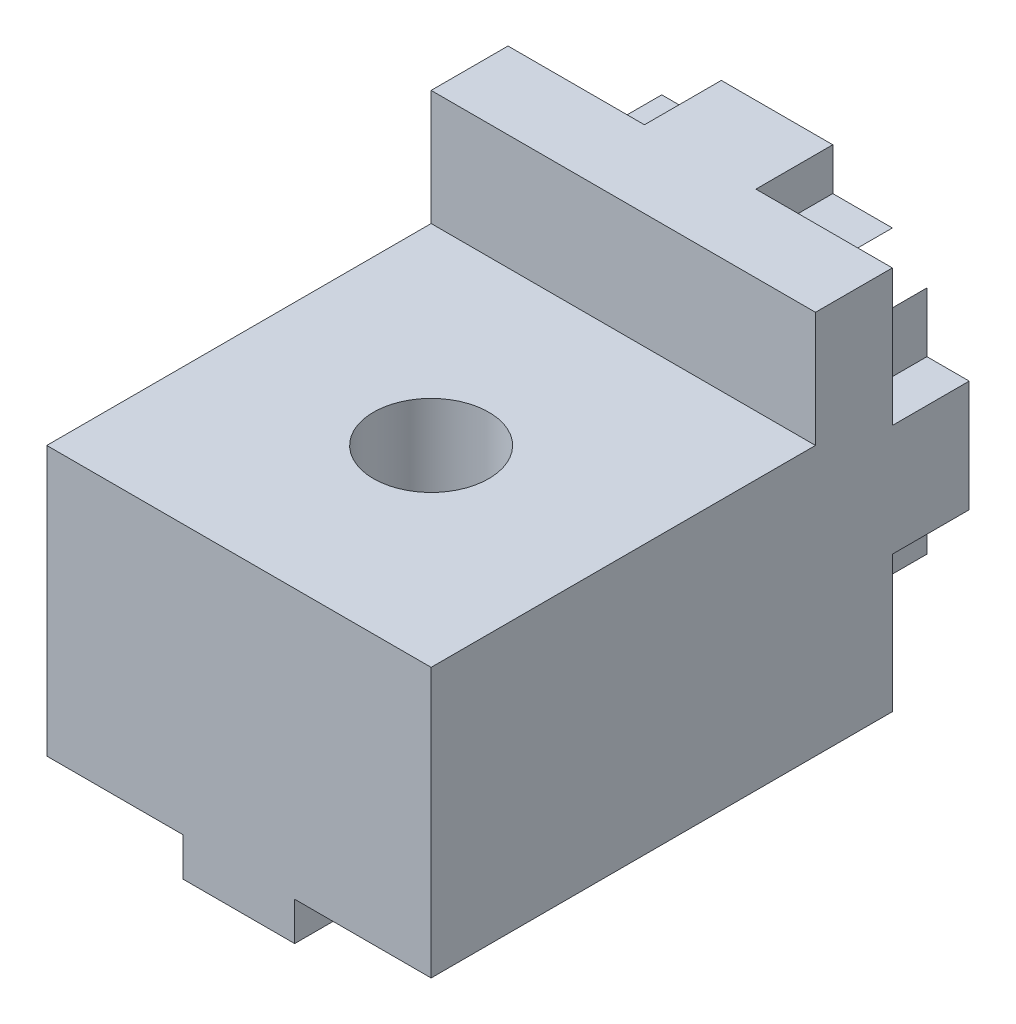
from build123d import *

# Parameters (mm, degrees)
SKETCH1_W                         = 10
SKETCH1_H                         = 10
MAIN_DEPTH                        = 12
ANTIROTATIONSYSTEM_DEPTH          = 2
CIRPATTERN1_COUNT                 = 4
SKETCH3_W                         = 10
SKETCH3_H                         = 10
MAKERBEAMSQUAREHOLEFORSCREW_DEPTH = 3
SKETCH5_W                         = 2.9
SKETCH5_H                         = 12
MAKERBEAMRAIL_DEPTH               = 1
SKETCH4_R                         = 1.5
VERTICALMAKERBEAMHOLE_DEPTH       = 16.264337522


with BuildPart() as part:
    # Sketch1 → Main (new body)
    with BuildSketch(Plane.XY):
        Rectangle(SKETCH1_W, SKETCH1_H)
    extrude(amount=MAIN_DEPTH)

    # Sketch2 → AntiRotationSystem (add)
    with BuildSketch(Plane(origin=(0, 0, 0), x_dir=(-1, 0, 0), z_dir=(0, 0, -1))):
        Polygon((-5, 1.45), (-3.9, 1.45), (-3.9, 3), (-2.1, 0.95), (-2.1, -0.95), (-3.9, -3), (-3.9, -1.45), (-5, -1.45), align=None)
    antirotationsystem = extrude(amount=ANTIROTATIONSYSTEM_DEPTH)

    # CirPattern1: AntiRotationSystem ×4 about axis
    cirpattern1_axis = Axis((0, 0, -1.2), (0, 0, 1))
    for i in range(1, CIRPATTERN1_COUNT):
        add(antirotationsystem.rotate(cirpattern1_axis, i * 360 / CIRPATTERN1_COUNT))

    # Sketch3 → MakerBeamSquareHoleForScrew (cut)
    with BuildSketch(Plane(origin=(0, 5, 0), x_dir=(1, 0, 0), z_dir=(0, 1, 0))):
        with Locations((0, -7)):
            Rectangle(SKETCH3_W, SKETCH3_H)
    extrude(amount=-MAKERBEAMSQUAREHOLEFORSCREW_DEPTH, mode=Mode.SUBTRACT)

    # Sketch5 → MakerBeamRail (add)
    with BuildSketch(Plane(origin=(0, -5, 0), x_dir=(-1, 0, 0), z_dir=(0, -1, 0))):
        with Locations((0, -6)):
            Rectangle(SKETCH5_W, SKETCH5_H)
    extrude(amount=MAKERBEAMRAIL_DEPTH)

    # Sketch4 → VerticalMakerBeamHole (cut, through all)
    with BuildSketch(Plane(origin=(0, 2, 0), x_dir=(1, 0, 0), z_dir=(0, 1, 0))):
        with Locations((0, -7)):
            Circle(SKETCH4_R)
    extrude(amount=-VERTICALMAKERBEAMHOLE_DEPTH, mode=Mode.SUBTRACT)


solid = part.part
